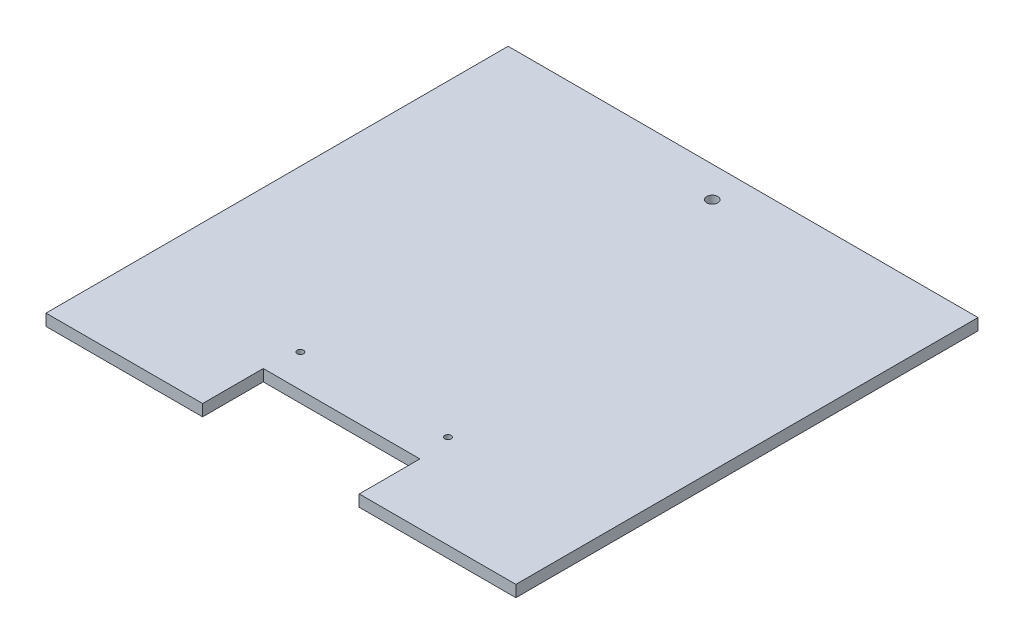
from build123d import *

# Parameters (mm, degrees)
SKETCH1_W           = 193.68
SKETCH1_H           = 190.5
BOSS_EXTRUDE1_DEPTH = 4.78
SKETCH2_R           = 2.286
CUT_EXTRUDE1_DEPTH  = 5.78
CUT_EXTRUDE2_DEPTH  = 5.78
SKETCH4_R           = 1.3
CUT_EXTRUDE4_DEPTH  = 5.78


with BuildPart() as part:
    # Sketch1 → Boss-Extrude1 (new body)
    with BuildSketch(Plane(origin=(0, 0, 0), x_dir=(1, 0, 0), z_dir=(0, 1, 0))):
        Rectangle(SKETCH1_W, SKETCH1_H)
    extrude(amount=BOSS_EXTRUDE1_DEPTH)

    # Sketch2 → Cut-Extrude1 (cut, through all)
    with BuildSketch(Plane(origin=(0, 4.78, 0), x_dir=(1, 0, 0), z_dir=(0, 1, 0))):
        with Locations((0, 82.55)):
            Circle(SKETCH2_R)
    extrude(amount=-CUT_EXTRUDE1_DEPTH, mode=Mode.SUBTRACT)

    # Sketch3 → Cut-Extrude2 (cut, through all)
    with BuildSketch(Plane(origin=(0, 4.78, 0), x_dir=(1, 0, 0), z_dir=(0, 1, 0))):
        Polygon((0, -95.25), (-32.28, -95.25), (-32.28, -70.249999962), (32.28, -70.249999962), (32.28, -95.25), align=None)
    extrude(amount=-CUT_EXTRUDE2_DEPTH, mode=Mode.SUBTRACT)

    # Sketch4 → Cut-Extrude4 (cut, through all)
    with BuildSketch(Plane(origin=(0, 4.78, 0), x_dir=(1, 0, 0), z_dir=(0, 1, 0))):
        with Locations((-30.511, -56.699999962)):
            Circle(SKETCH4_R)
        with Locations((30.289, -56.699999962)):
            Circle(SKETCH4_R)
    extrude(amount=-CUT_EXTRUDE4_DEPTH, mode=Mode.SUBTRACT)


solid = part.part
